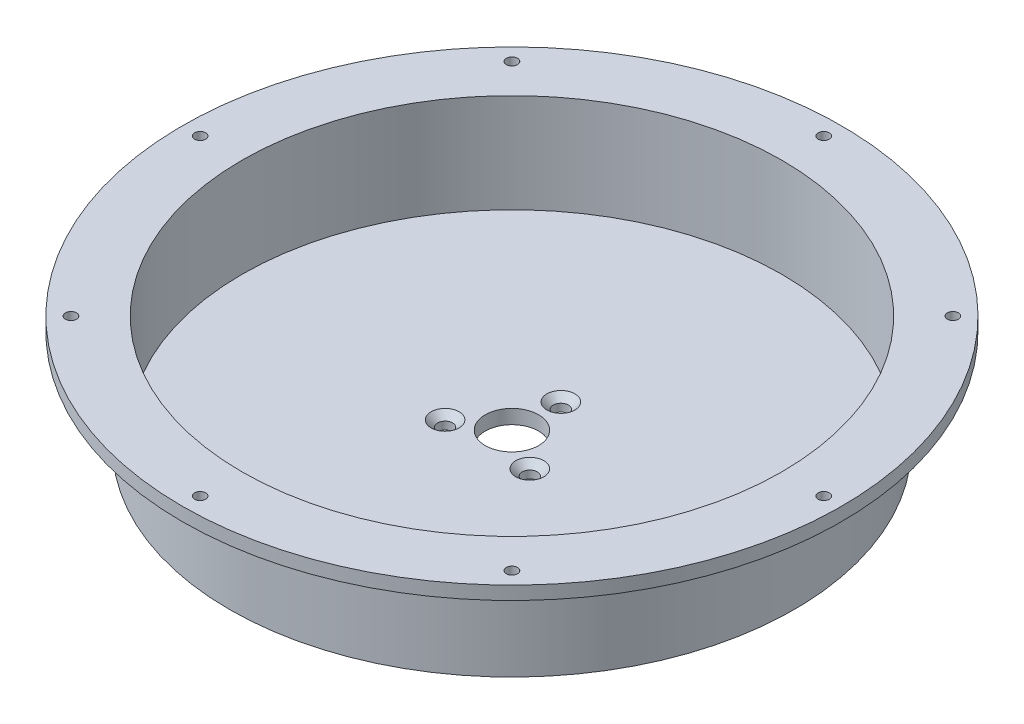
from build123d import *

# Parameters (mm, degrees)
SKETCH1_R                                       = 63.5
SKETCH1_R_2                                     = 60.690000065
BOSS_EXTRUDE1_DEPTH                             = 25.4
SKETCH3_R                                       = 63.5
BOSS_EXTRUDE2_DEPTH                             = 3.175
CUT_EXTRUDE1_REACH                              = 27.4
SKETCH8_R                                       = 6
SKETCH9_R                                       = 74.095000033
SKETCH9_R_2                                     = 63.5
BOSS_EXTRUDE4_DEPTH                             = 3
M3X0_5_TAPPED_HOLE1_D                           = 2.5
CIRPATTERN2_COUNT                               = 8
FILLET1_R                                       = 3
CSK_FOR_M3_FLAT_HEAD_MACHINE_SCREW1_D           = 3.4
CSK_FOR_M3_FLAT_HEAD_MACHINE_SCREW1_CSINK_D     = 6.3
CSK_FOR_M3_FLAT_HEAD_MACHINE_SCREW1_CSINK_ANGLE = 90
CIRPATTERN3_COUNT                               = 3


with BuildPart() as part:
    # Sketch1 → Boss-Extrude1 (new body)
    with BuildSketch(Plane(origin=(0, 0, 0), x_dir=(1, 0, 0), z_dir=(0, 1, 0))):
        Circle(SKETCH1_R)
        Circle(SKETCH1_R_2, mode=Mode.SUBTRACT)
    extrude(amount=BOSS_EXTRUDE1_DEPTH)

    # Sketch3 → Boss-Extrude2 (add)
    with BuildSketch(Plane(origin=(0, 0, 0), x_dir=(1, 0, 0), z_dir=(0, 1, 0))):
        Circle(SKETCH3_R)
    extrude(amount=BOSS_EXTRUDE2_DEPTH)

    # Sketch8 → Cut-Extrude1 (cut, up to next)
    with BuildSketch(Plane.XZ, mode=Mode.PRIVATE) as cut_extrude1_sk1:
        Circle(SKETCH8_R)
    cut_extrude1_tool1 = extrude(cut_extrude1_sk1.sketch, amount=-CUT_EXTRUDE1_REACH, mode=Mode.PRIVATE) & part.part
    add(cut_extrude1_tool1.solids().sort_by_distance((0, 0, 0))[0], mode=Mode.SUBTRACT)

    # Sketch9 → Boss-Extrude4 (add)
    with BuildSketch(Plane(origin=(0, 25.4, 0), x_dir=(1, 0, 0), z_dir=(0, 1, 0))):
        Circle(SKETCH9_R)
        Circle(SKETCH9_R_2, mode=Mode.SUBTRACT)
    extrude(amount=-BOSS_EXTRUDE4_DEPTH)

    # M3x0.5 Tapped Hole1 (through all)
    with Locations(Plane(origin=(0, 25.4, 0), x_dir=(1, 0, 0), z_dir=(0, 1, 0))):
        with Locations((0, 70.1)):
            m3x0_5_tapped_hole1 = Hole(M3X0_5_TAPPED_HOLE1_D / 2)

    # CirPattern2: M3x0.5 Tapped Hole1 ×8 about axis
    cirpattern2_axis = Axis((0, 0, 0), (0, 1, 0))
    for i in range(1, CIRPATTERN2_COUNT):
        add(m3x0_5_tapped_hole1.rotate(cirpattern2_axis, i * 360 / CIRPATTERN2_COUNT), mode=Mode.SUBTRACT)

    # Fillet1
    fillet1_edges = [part.edges().sort_by_distance(p)[0] for p in [
        (-63.5, 22.4, 0),
    ]]
    fillet(fillet1_edges, radius=FILLET1_R)

    # CSK for M3 Flat Head Machine Screw1 (through all)
    with Locations(Plane(origin=(0, 3.175, 0), x_dir=(1, 0, 0), z_dir=(0, 1, 0))):
        with Locations((0, 11)):
            csk_for_m3_flat_head_machine_screw1 = CounterSinkHole(CSK_FOR_M3_FLAT_HEAD_MACHINE_SCREW1_D / 2, CSK_FOR_M3_FLAT_HEAD_MACHINE_SCREW1_CSINK_D / 2, counter_sink_angle=CSK_FOR_M3_FLAT_HEAD_MACHINE_SCREW1_CSINK_ANGLE)

    # CirPattern3: CSK for M3 Flat Head Machine Screw1 ×3 about axis
    cirpattern3_axis = Axis((0, 0, 0), (0, 1, 0))
    for i in range(1, CIRPATTERN3_COUNT):
        add(csk_for_m3_flat_head_machine_screw1.rotate(cirpattern3_axis, i * 360 / CIRPATTERN3_COUNT), mode=Mode.SUBTRACT)


solid = part.part
